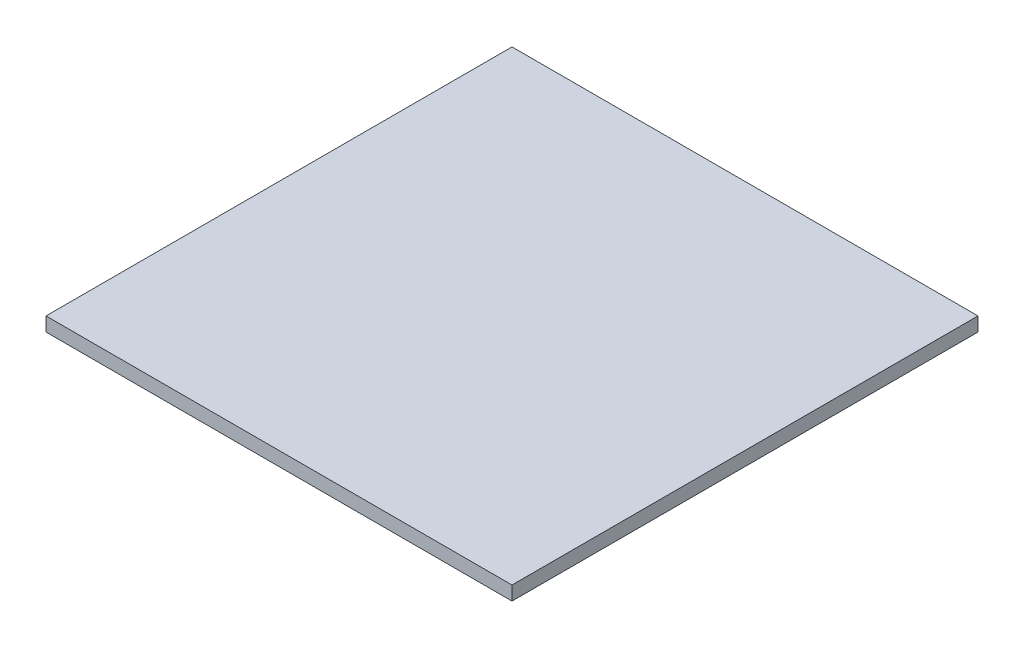
from build123d import *

# Parameters (mm, degrees)
SKETCH_1_W      = 100
SKETCH_1_H      = 100
EXTRUDE_1_DEPTH = 3


with BuildPart() as part:
    # 草图1 → 凸台-拉伸1 (new body)
    with BuildSketch(Plane(origin=(0, 0, 0), x_dir=(1, 0, 0), z_dir=(0, 1, 0))):
        Rectangle(SKETCH_1_W, SKETCH_1_H)
    extrude(amount=EXTRUDE_1_DEPTH)


solid = part.part
